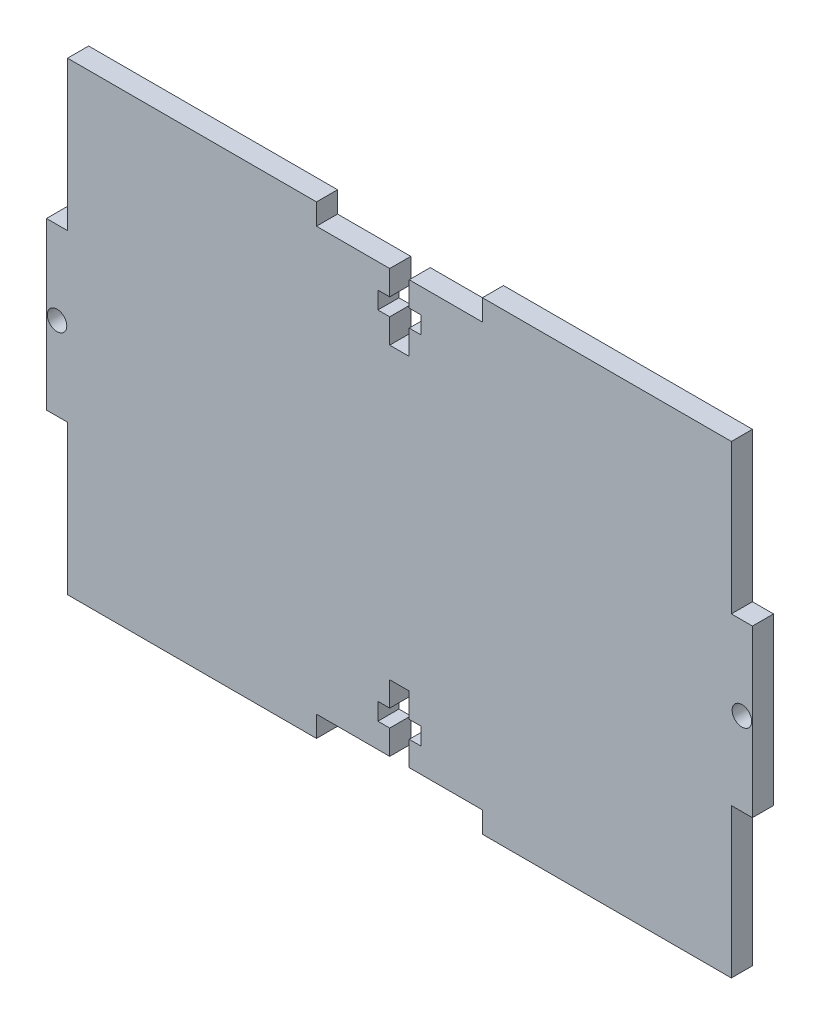
from build123d import *

# Parameters (mm, degrees)
SKETCH1_R           = 1.47
BOSS_EXTRUDE1_DEPTH = 1.5875


with BuildPart() as part:
    # Sketch1 → Boss-Extrude1 (new body, symmetric)
    with BuildSketch(Plane.XY):
        Polygon((-12.5, 35), (-50, 35), (-50, 12.5), (-53.175, 12.5), (-53.175, -12.5), (-50, -12.5), (-50, -35), (-12.5, -35), (-12.5, -31.825), (-1.47, -31.825), (-1.47, -28.125), (-3.25, -28.125), (-3.25, -25.525), (-1.47, -25.525), (-1.47, -21.825), (1.47, -21.825), (1.47, -25.525), (3.25, -25.525), (3.25, -28.125), (1.47, -28.125), (1.47, -31.825), (12.5, -31.825), (12.5, -35), (50, -35), (50, -12.5), (53.175, -12.5), (53.175, 12.5), (50, 12.5), (50, 35), (12.5, 35), (12.5, 31.825), (1.47, 31.825), (1.47, 28.125), (3.25, 28.125), (3.25, 25.525), (1.47, 25.525), (1.47, 21.825), (-1.47, 21.825), (-1.47, 25.525), (-3.25, 25.525), (-3.25, 28.125), (-1.47, 28.125), (-1.47, 31.825), (-12.5, 31.825), align=None)
        with Locations((-51.5875, 0)):
            Circle(SKETCH1_R, mode=Mode.SUBTRACT)
        with Locations((51.5875, 0)):
            Circle(SKETCH1_R, mode=Mode.SUBTRACT)
    extrude(amount=BOSS_EXTRUDE1_DEPTH, both=True)


solid = part.part
